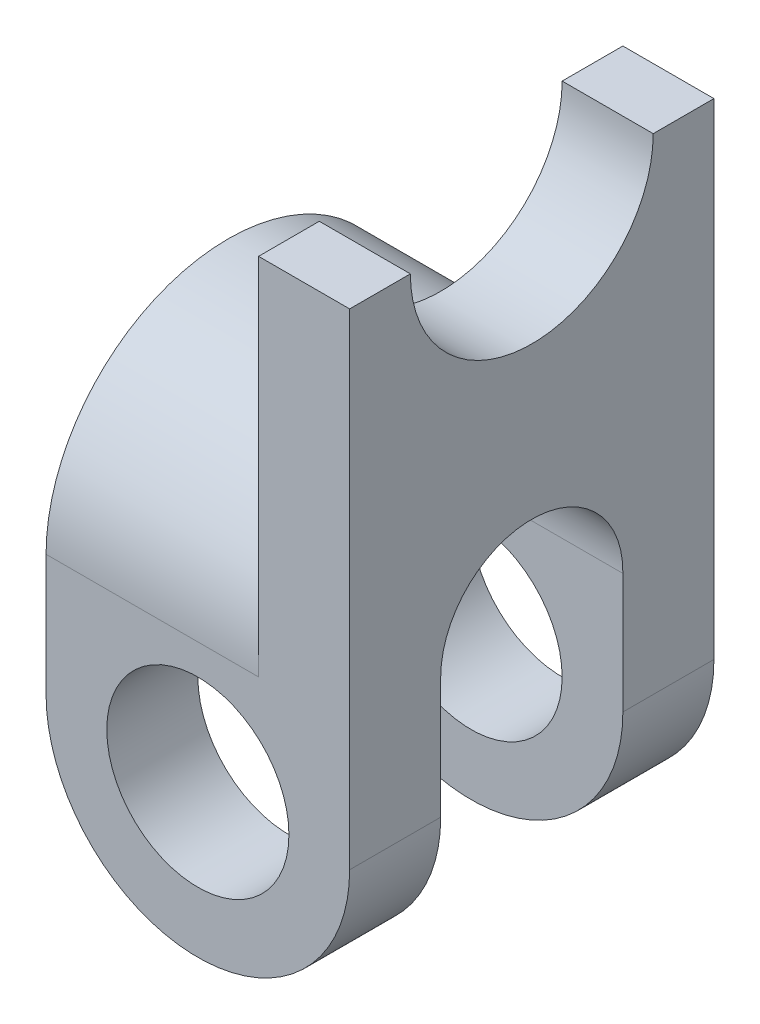
from build123d import *

# Parameters (mm, degrees)
SKETCH1_R           = 15
BOSS_EXTRUDE1_DEPTH = 30
SKETCH2_R           = 20
CUT_EXTRUDE1_DEPTH  = 16
BOSS_EXTRUDE2_DEPTH = 35
CUT_EXTRUDE3_DEPTH  = 51


with BuildPart() as part:
    # Sketch1 → Boss-Extrude1 (new body, symmetric)
    with BuildSketch(Plane.XY):
        with BuildLine():
            Line((25, 0), (25, 80))
            Line((25, 80), (10, 80))
            Line((10, 80), (10, 22.912878475))
            Line((10, 22.912878475), (10, 20))
            Line((10, 20), (-25, 20))
            Line((-25, 20), (-25, 0))
            ThreePointArc((-25, 0), (0, -25), (25, 0))
        make_face()
        Circle(SKETCH1_R, mode=Mode.SUBTRACT)
    extrude(amount=BOSS_EXTRUDE1_DEPTH, both=True)

    # Sketch2 → Cut-Extrude1 (cut, through all)
    with BuildSketch(Plane.ZY.offset(-10)):
        with Locations((0, 80)):
            Circle(SKETCH2_R)
    extrude(amount=-CUT_EXTRUDE1_DEPTH, mode=Mode.SUBTRACT)

    # Sketch4 → Boss-Extrude2 (add)
    with BuildSketch(Plane.ZY.offset(25)):
        with BuildLine():
            Line((-15, 20), (-30, 20))
            ThreePointArc((-30, 20), (0, 50), (30, 20))
            Line((30, 20), (15, 20))
            ThreePointArc((15, 20), (0, 35), (-15, 20))
        make_face()
    extrude(amount=-BOSS_EXTRUDE2_DEPTH)

    # Sketch5 → Cut-Extrude3 (cut, through all)
    with BuildSketch(Plane.ZY.offset(25)):
        with BuildLine():
            Line((-15, 19.774418989), (-15, -47.367007727))
            Line((-15, -47.367007727), (15.001696131, -47.367007727))
            Line((15.001696131, -47.367007727), (15.001696131, -44.584519051))
            Line((15.001696131, -44.584519051), (15.001696131, 20))
            ThreePointArc((15.001696131, 20), (-0.112793694, 35.001272092), (-15, 19.774418989))
        make_face()
    extrude(amount=-CUT_EXTRUDE3_DEPTH, mode=Mode.SUBTRACT)


solid = part.part
